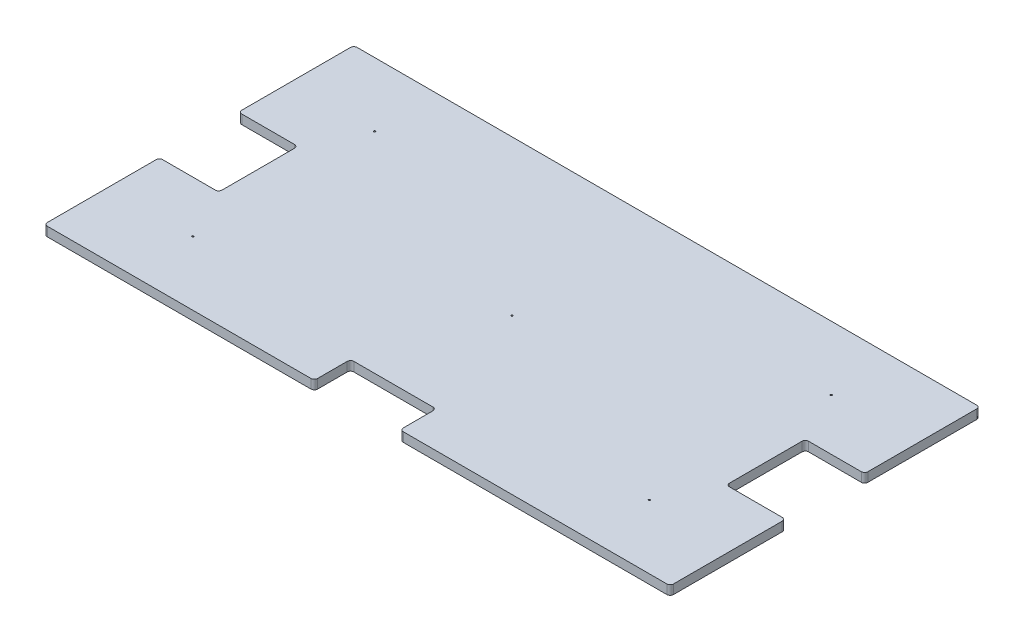
from build123d import *

# Parameters (mm, degrees)
SKETCH1_W                    = 1206.5
SKETCH1_H                    = 596.9
BOSS_EXTRUDE1_DEPTH          = 17.78
FILLET1_R                    = 6.35
SKETCH4_W                    = 165.1
SKETCH4_H                    = 69.85
SKETCH4_W_2                  = 114.3
SKETCH4_H_2                  = 152.4
CUT_EXTRUDE1_DEPTH           = 18.78
FILLET2_R                    = 6.35
F_1_8_0_125_DIAMETER_HOLE2_D = 3.175


with BuildPart() as part:
    # Sketch1 → Boss-Extrude1 (new body)
    with BuildSketch(Plane(origin=(0, 0, 0), x_dir=(1, 0, 0), z_dir=(0, 1, 0))):
        Rectangle(SKETCH1_W, SKETCH1_H)
    extrude(amount=BOSS_EXTRUDE1_DEPTH)

    # Fillet1
    fillet1_edges = [part.edges().sort_by_distance(p)[0] for p in [
        (603.25, 8.89, 298.45),
        (-603.25, 8.89, 298.45),
        (-603.25, 8.89, -298.45),
        (603.25, 8.89, -298.45),
    ]]
    fillet(fillet1_edges, radius=FILLET1_R)

    # Sketch4 → Cut-Extrude1 (cut, through all)
    with BuildSketch(Plane(origin=(0, 17.78, 0), x_dir=(1, 0, 0), z_dir=(0, 1, 0))):
        with Locations((0, -263.525)):
            Rectangle(SKETCH4_W, SKETCH4_H)
        with Locations((-546.1, 0)):
            Rectangle(SKETCH4_W_2, SKETCH4_H_2)
        with Locations((546.1, 0)):
            Rectangle(SKETCH4_W_2, SKETCH4_H_2)
    extrude(amount=-CUT_EXTRUDE1_DEPTH, mode=Mode.SUBTRACT)

    # Fillet2
    fillet2_edges = [part.edges().sort_by_distance(p)[0] for p in [
        (82.55, 8.89, 228.6),
        (82.55, 8.89, 298.45),
        (-82.55, 8.89, 298.45),
        (-82.55, 8.89, 228.6),
        (-603.25, 8.89, 76.2),
        (-603.25, 8.89, -76.2),
        (-488.95, 8.89, -76.2),
        (-488.95, 8.89, 76.2),
        (603.25, 8.89, -76.2),
        (603.25, 8.89, 76.2),
        (488.95, 8.89, 76.2),
        (488.95, 8.89, -76.2),
    ]]
    fillet(fillet2_edges, radius=FILLET2_R)

    # 1/8 (0.125) Diameter Hole2 (through all)
    with Locations(Plane(origin=(0, 0, 0), x_dir=(-1, 0, 0), z_dir=(0, -1, 0))):
        with Locations((-439.865615282, 175.258956089), (439.865615282, 175.258956089), (439.865615282, -175.258956089), (0, 0), (-439.865615282, -175.258956089)):
            Hole(F_1_8_0_125_DIAMETER_HOLE2_D / 2)


solid = part.part
